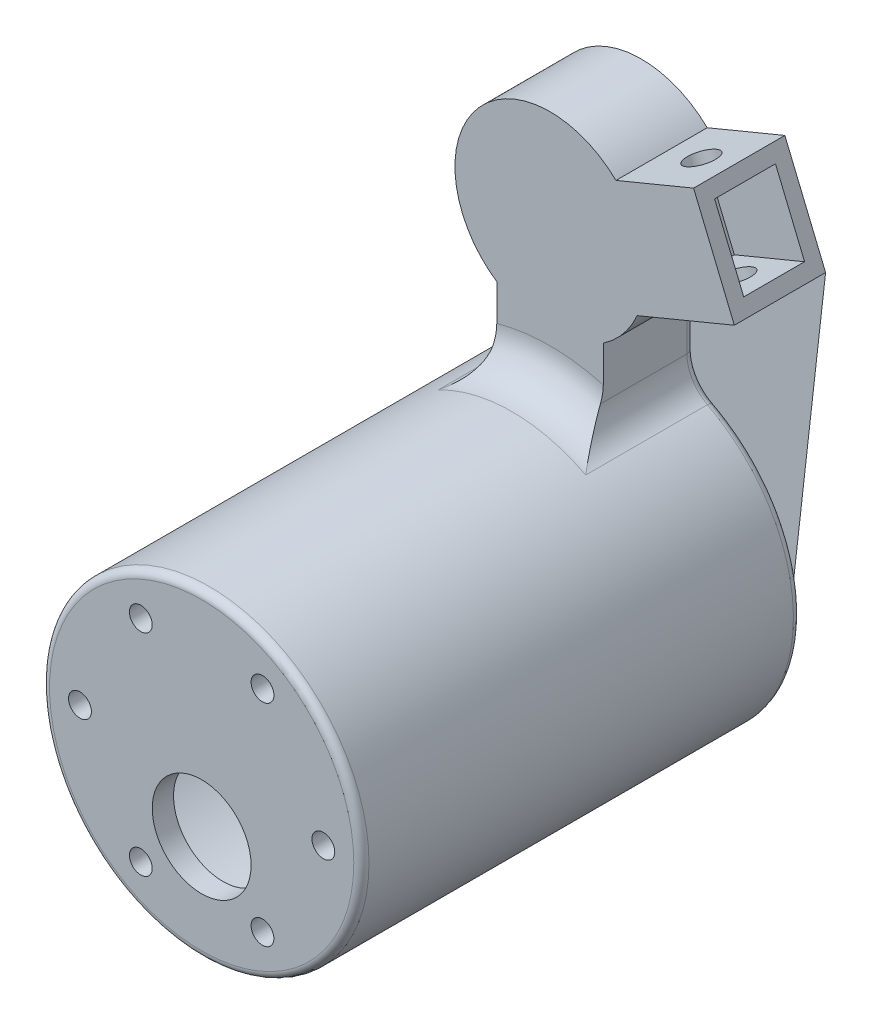
from build123d import *

# Parameters (mm, degrees)
SKETCH1_R           = 12.5
BOSS_EXTRUDE2_DEPTH = 12
BOSS_EXTRUDE3_DEPTH = 12
SKETCH3_W           = 8
SKETCH3_H           = 10
CUT_EXTRUDE1_DEPTH  = 10
SKETCH4_R           = 2
CUT_EXTRUDE2_DEPTH  = 34.07960813
SKETCH5_R           = 21.000952359
BOSS_EXTRUDE4_DEPTH = 57.8
SKETCH6_R           = 19
CUT_EXTRUDE3_DEPTH  = 55
SKETCH7_R           = 6.5
SKETCH7_R_2         = 1.5
CUT_EXTRUDE4_DEPTH  = 58.8
FILLET1_R           = 5
FILLET2_R           = 1


with BuildPart() as part:
    # Sketch1 → Boss-Extrude2 (new body)
    with BuildSketch(Plane.XY):
        Circle(SKETCH1_R)
    extrude(amount=BOSS_EXTRUDE2_DEPTH)

    # Sketch2 → Boss-Extrude3 (add)
    with BuildSketch(Plane.XY):
        with BuildLine():
            Line((24.231440373, 0.295461436), (11.458506302, -4.995261088))
            ThreePointArc((11.458506302, -4.995261088), (12.259311424, 2.441164357), (8.670952565, 9.003587153))
            Line((8.670952565, 9.003587153), (18.87387232, 13.229774891))
            Line((18.87387232, 13.229774891), (20.787289482, 8.610377228))
            Line((20.787289482, 8.610377228), (24.231440373, 0.295461436))
        make_face()
        with BuildLine():
            Line((7, -10.356157589), (7, -20.356157589))
            Line((7, -20.356157589), (-7, -20.356157589))
            Line((-7, -20.356157589), (-7, -10.356157589))
            ThreePointArc((-7, -10.356157589), (0, -12.5), (7, -10.356157589))
        make_face()
    extrude(amount=BOSS_EXTRUDE3_DEPTH)

    # Sketch3 → Cut-Extrude1 (cut)
    with BuildSketch(Plane(origin=(20.787289482, 8.610377228, 0), x_dir=(0, 0, -1), z_dir=(0.923879533, 0.382683432, 0))):
        with Locations((-6, -2)):
            Rectangle(SKETCH3_W, SKETCH3_H)
    extrude(amount=-CUT_EXTRUDE1_DEPTH, mode=Mode.SUBTRACT)

    # Sketch4 → Cut-Extrude2 (cut, through all)
    with BuildSketch(Plane(origin=(-1.913417162, 4.619397663, 0), x_dir=(0.923879533, 0.382683432, 0), z_dir=(-0.382683432, 0.923879533, 0))):
        with Locations((17.119244795, -6)):
            Circle(SKETCH4_R)
    extrude(amount=-CUT_EXTRUDE2_DEPTH, mode=Mode.SUBTRACT)

    # Sketch5 → Boss-Extrude4 (add)
    with BuildSketch(Plane.XY):
        with Locations((0, -40.156157589)):
            Circle(SKETCH5_R)
    extrude(amount=BOSS_EXTRUDE4_DEPTH)

    # Sketch6 → Cut-Extrude3 (cut)
    with BuildSketch(Plane(origin=(0, 0, 0), x_dir=(-1, 0, 0), z_dir=(0, 0, -1))):
        with Locations((0, -40.156157589)):
            Circle(SKETCH6_R)
    extrude(amount=-CUT_EXTRUDE3_DEPTH, mode=Mode.SUBTRACT)

    # Sketch7 → Cut-Extrude4 (cut, through all)
    with BuildSketch(Plane.XY.offset(57.8)):
        with Locations((0, -47.156157589)):
            Circle(SKETCH7_R)
        with Locations((-16, -40.156157589)):
            Circle(SKETCH7_R_2)
        with Locations((-8, -54.012564049)):
            Circle(SKETCH7_R_2)
        with Locations((8, -54.012564049)):
            Circle(SKETCH7_R_2)
        with Locations((16, -40.156157589)):
            Circle(SKETCH7_R_2)
        with Locations((8, -26.299751128)):
            Circle(SKETCH7_R_2)
        with Locations((-8, -26.299751128)):
            Circle(SKETCH7_R_2)
    extrude(amount=-CUT_EXTRUDE4_DEPTH, mode=Mode.SUBTRACT)

    # Fillet1
    fillet1_edges = [part.edges().sort_by_distance(p)[0] for p in [
        (-7, -20.356157589, 6),
        (7, -20.356157589, 6),
        (0, -19.155205229, 12),
    ]]
    fillet(fillet1_edges, radius=FILLET1_R)

    # Fillet2
    fillet2_edges = [part.edges().sort_by_distance(p)[0] for p in [
        (7, -13.723058226, 0),
        (-10.897030164, -58.108726586, 0),
        (7.725772648, -19.684372198, 0),
        (-7.725772648, -19.684372198, 0),
        (-7, -13.723058226, 0),
        (-21.000952359, -40.156157589, 57.8),
        (19, -40.156157589, 0),
    ]]
    fillet(fillet2_edges, radius=FILLET2_R)


solid = part.part
